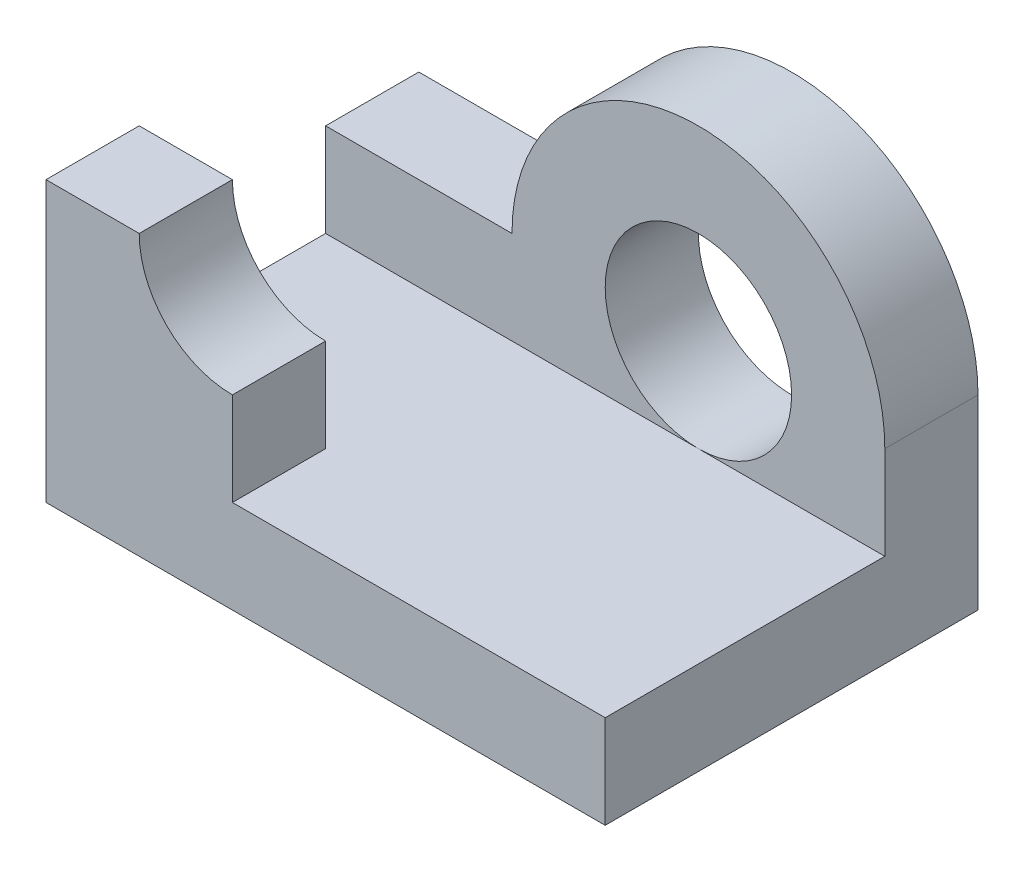
from build123d import *

# Parameters (mm, degrees)
SKETCH1_W           = 60
SKETCH1_H           = 40
BOSS_EXTRUDE1_DEPTH = 10
BOSS_EXTRUDE2_DEPTH = 10
SKETCH3_R           = 10
CUT_EXTRUDE1_DEPTH  = 10
BOSS_EXTRUDE3_DEPTH = 10


with BuildPart() as part:
    # Sketch1 → Boss-Extrude1 (new body)
    with BuildSketch(Plane(origin=(0, 0, 0), x_dir=(1, 0, 0), z_dir=(0, 1, 0))):
        with Locations((-30, 20)):
            Rectangle(SKETCH1_W, SKETCH1_H)
    extrude(amount=BOSS_EXTRUDE1_DEPTH)

    # Sketch2 → Boss-Extrude2 (add)
    with BuildSketch(Plane(origin=(0, 0, -40), x_dir=(-1, 0, 0), z_dir=(0, 0, -1))):
        with BuildLine():
            Line((0, 10), (0, 20))
            ThreePointArc((0, 20), (20, 40), (40, 20))
            Line((40, 20), (60, 20))
            Line((60, 20), (60, 10))
            Line((60, 10), (0, 10))
        make_face()
    extrude(amount=-BOSS_EXTRUDE2_DEPTH)

    # Sketch3 → Cut-Extrude1 (cut)
    with BuildSketch(Plane.XY.offset(-30)):
        with Locations((-20, 20)):
            Circle(SKETCH3_R)
    extrude(amount=-CUT_EXTRUDE1_DEPTH, mode=Mode.SUBTRACT)

    # Sketch4 → Boss-Extrude3 (add)
    with BuildSketch(Plane.XY):
        with BuildLine():
            Line((-60, 10), (-60, 30))
            Line((-60, 30), (-50, 30))
            ThreePointArc((-50, 30), (-47.071067812, 22.928932188), (-40, 20))
            Line((-40, 20), (-40, 10))
            Line((-40, 10), (-60, 10))
        make_face()
    extrude(amount=-BOSS_EXTRUDE3_DEPTH)


solid = part.part
